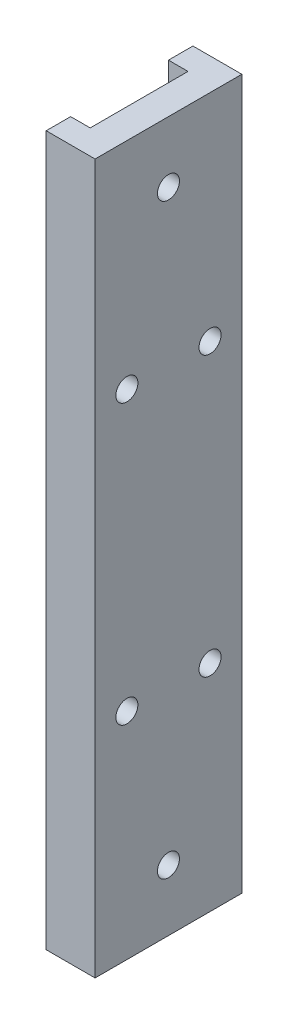
from build123d import *

# Parameters (mm, degrees)
BOSS_EXTRUDE1_DEPTH  = 145
M4_CLEARANCE_HOLE1_D = 4.5
HOLE1_D              = 4.5
HOLE1_DEPTH          = 6


with BuildPart() as part:
    # Sketch1 → Boss-Extrude1 (new body)
    with BuildSketch(Plane(origin=(0, 260, 0), x_dir=(-1, 0, 0), z_dir=(0, -1, 0))):
        Polygon((71.5, -127.5), (61.5, -127.5), (61.5, -97.5), (71.5, -97.5), (71.5, -102.5), (67.5, -102.5), (67.5, -122.5), (71.5, -122.5), align=None)
    extrude(amount=BOSS_EXTRUDE1_DEPTH)

    # M4 Clearance Hole1 (through all)
    with Locations(Plane(origin=(-61.5, 0, 0), x_dir=(0, 0, -1), z_dir=(1, 0, 0))):
        with Locations((-112.5, 247.5), (-112.5, 127.5)):
            Hole(M4_CLEARANCE_HOLE1_D / 2)

    # Hole1
    with Locations(Plane(origin=(-61.5, 0, 0), x_dir=(0, 0, -1), z_dir=(1, 0, 0))):
        with Locations((-104, 216), (-121, 216), (-104, 159), (-121, 159)):
            Hole(HOLE1_D / 2, depth=HOLE1_DEPTH)


solid = part.part
